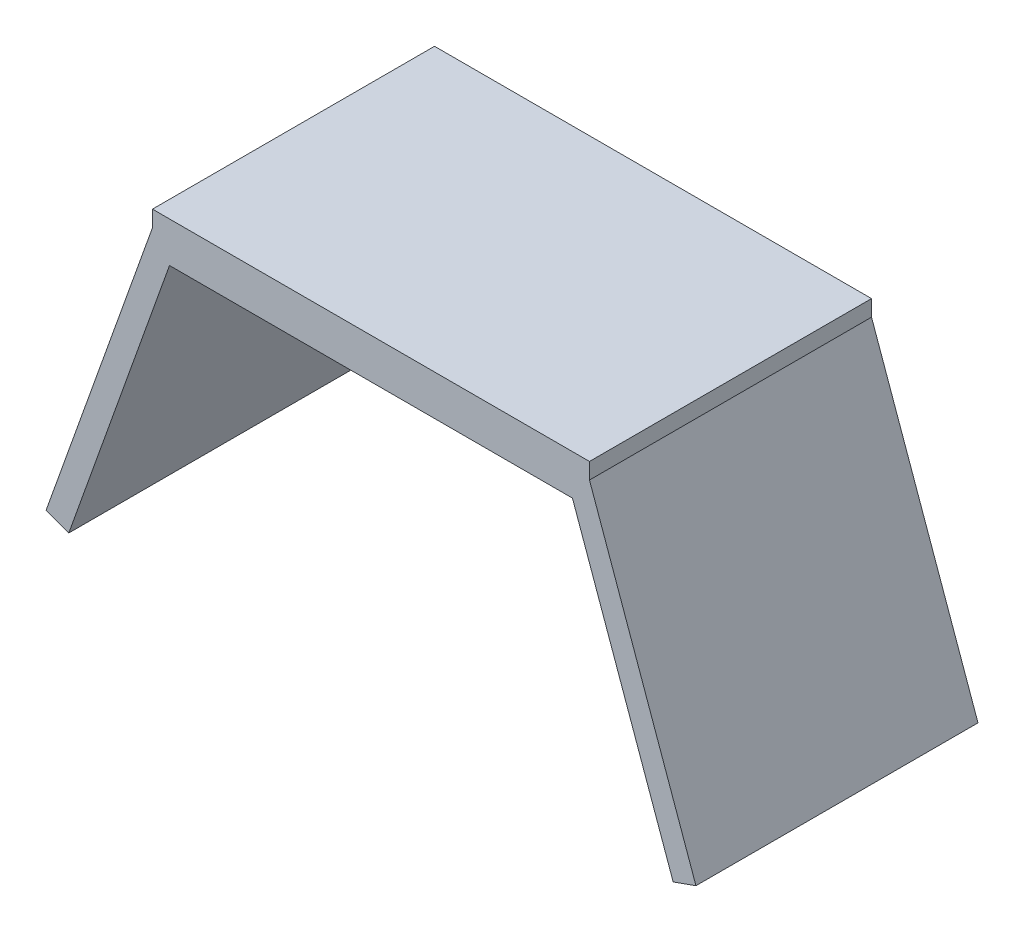
from build123d import *

# Parameters (mm, degrees)
BOSS_EXTRUDE2_DEPTH = 35


with BuildPart() as part:
    # Sketch2 → Boss-Extrude2 (new body)
    with BuildSketch(Plane.XY):
        Polygon((-25, 0), (25, 0), (37.5, -35), (40.325225735, -33.990990809), (27.114157589, 3), (27.114157589, 5), (-27.114157589, 5), (-27.114157589, 3), (-40.325225735, -33.990990809), (-37.5, -35), align=None)
    extrude(amount=BOSS_EXTRUDE2_DEPTH)


solid = part.part
